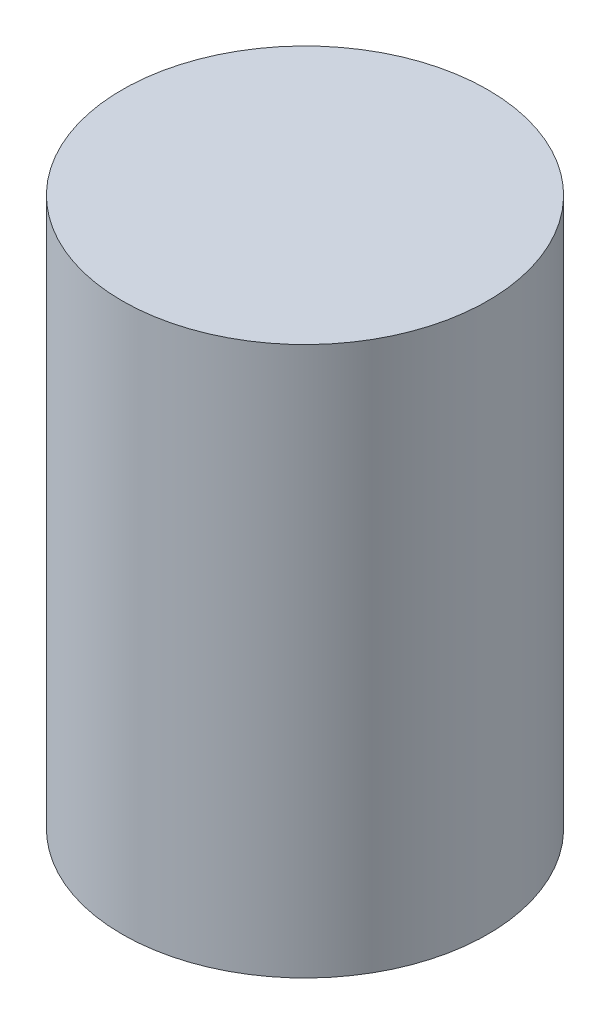
from build123d import *

# Parameters (mm, degrees)
SKETCH1_R           = 10
BOSS_EXTRUDE1_DEPTH = 30


with BuildPart() as part:
    # Sketch1 → Boss-Extrude1 (new body)
    with BuildSketch(Plane(origin=(0, 0, 0), x_dir=(1, 0, 0), z_dir=(0, 1, 0))):
        Circle(SKETCH1_R)
    extrude(amount=BOSS_EXTRUDE1_DEPTH)


solid = part.part
